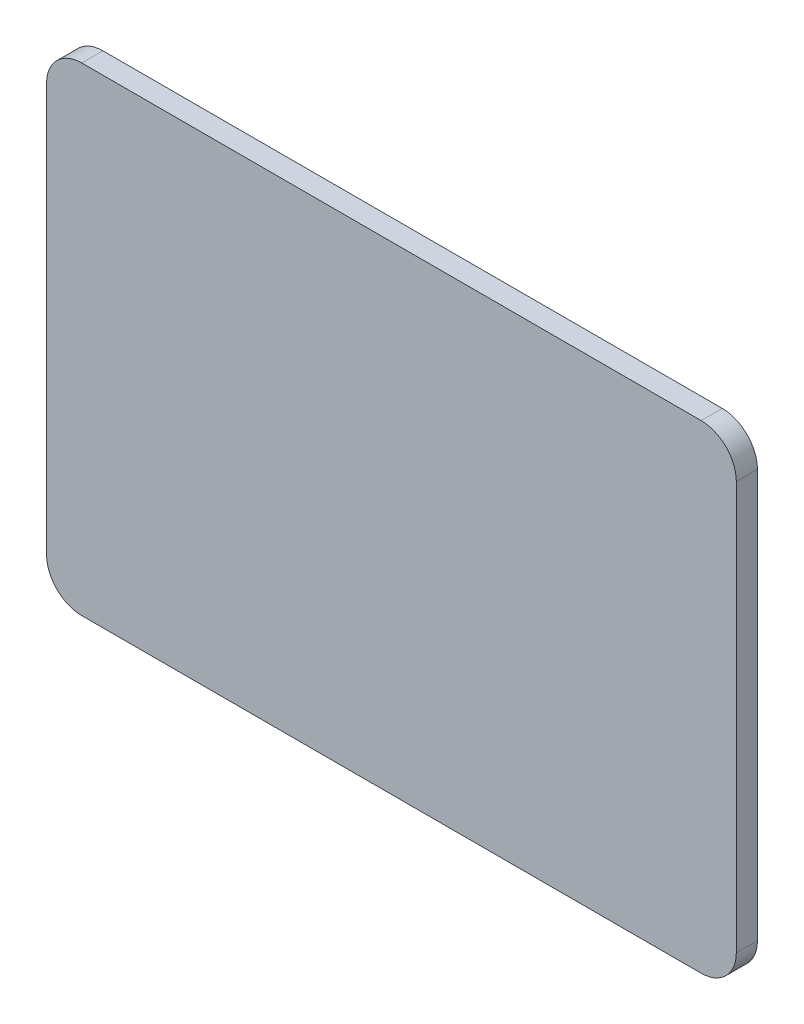
from build123d import *

# Parameters (mm, degrees)
BOSS_EXTRUDE1_DEPTH = 7.62


with BuildPart() as part:
    # Sketch1 → Boss-Extrude1 (new body)
    with BuildSketch(Plane.XY):
        with BuildLine():
            Line((-111.76, -86.36), (111.76, -86.36))
            ThreePointArc((111.76, -86.36), (120.740256121, -82.640256121), (124.46, -73.66))
            Line((124.46, -73.66), (124.46, 73.66))
            ThreePointArc((124.46, 73.66), (120.740256121, 82.640256121), (111.76, 86.36))
            Line((111.76, 86.36), (-111.76, 86.36))
            ThreePointArc((-111.76, 86.36), (-120.740256121, 82.640256121), (-124.46, 73.66))
            Line((-124.46, 73.66), (-124.46, -73.66))
            ThreePointArc((-124.46, -73.66), (-120.740256121, -82.640256121), (-111.76, -86.36))
        make_face()
    extrude(amount=BOSS_EXTRUDE1_DEPTH)


solid = part.part
